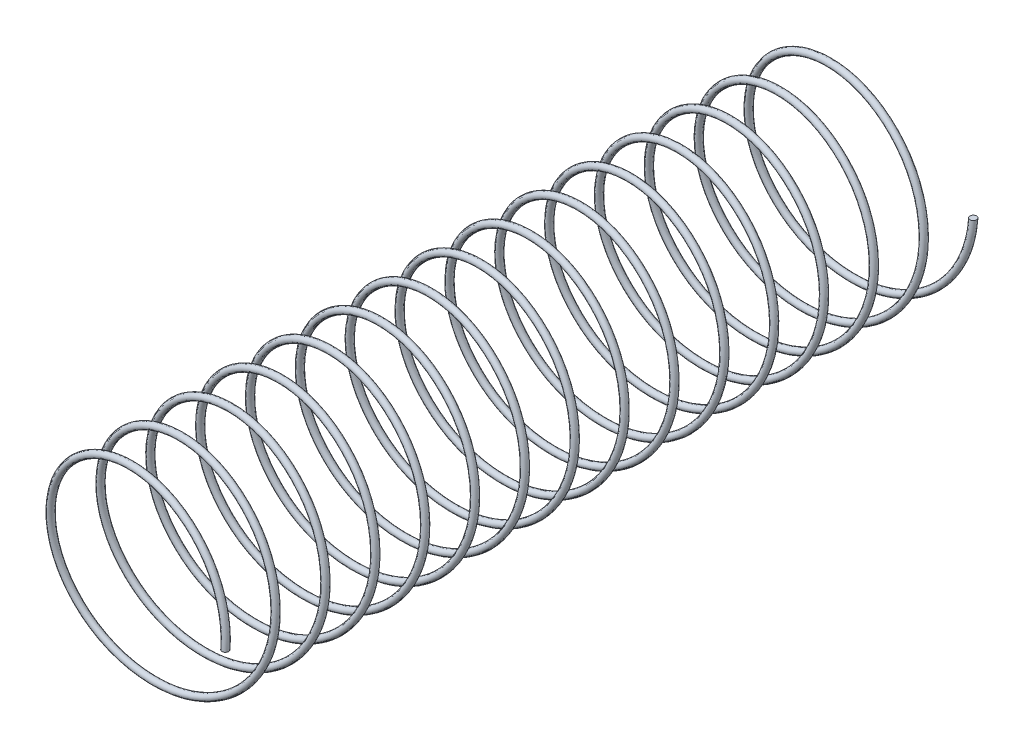
from build123d import *

# Parameters (mm, degrees)
SWEEP_1_PITCH  = 1.5
SWEEP_1_HEIGHT = 22.5
SWEEP_1_RADIUS = 3
SKETCH_2_R     = 0.1


with BuildPart() as part:
    # 扫描1: sweep along a helix
    with BuildLine() as sweep_1_path:
        Helix(SWEEP_1_PITCH, SWEEP_1_HEIGHT, SWEEP_1_RADIUS, center=(0, 0, 0), direction=(0, 0, 1), lefthand=True)
    # 草图2 → 扫描1 (sweep)
    with BuildSketch(Plane(origin=(0, 0, 0), x_dir=(1, 0, 0), z_dir=(0, 1, 0))):
        with Locations((3, -22.5)):
            Circle(SKETCH_2_R)
    sweep(path=sweep_1_path.line, is_frenet=True)


solid = part.part
